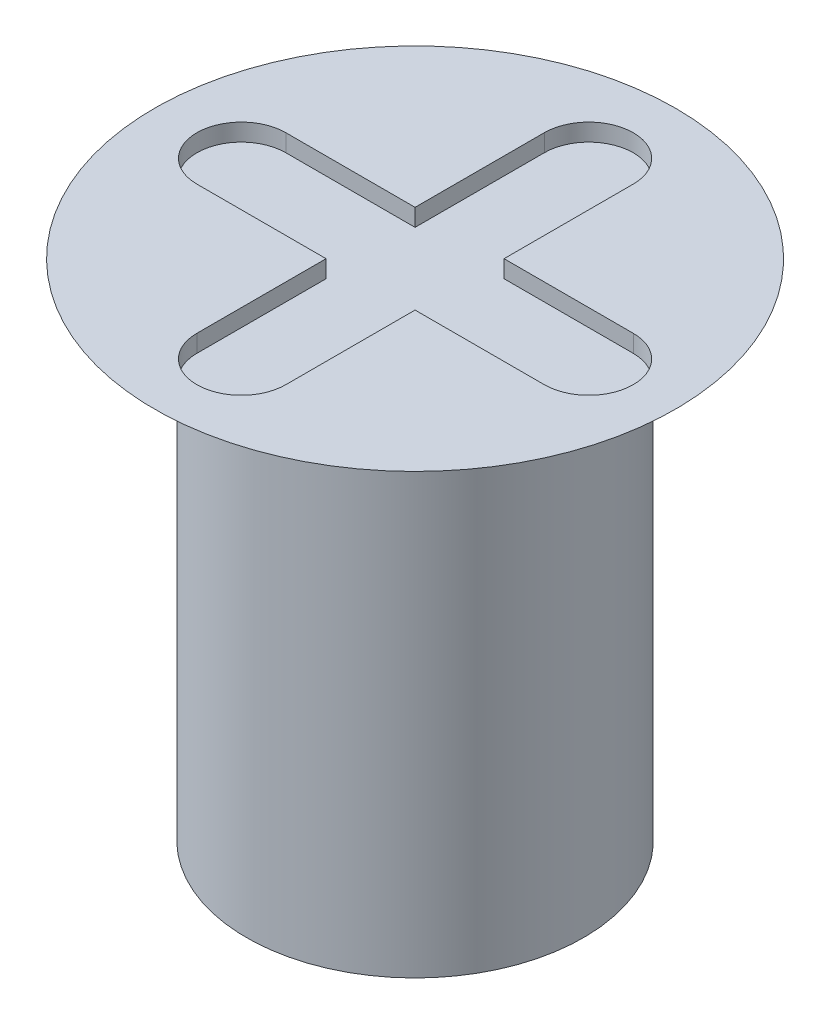
from build123d import *

# Parameters (mm, degrees)
CUT_EXTRUDE1_DEPTH = 0.1


with BuildPart() as part:
    # Sketch1 → Revolve1 (revolve)
    with BuildSketch(Plane.XY):
        Polygon((0, 2.9), (1.5, 2.9), (0.97, 2.594004357), (0.97, 0), (0, 0), align=None)
    revolve(axis=Axis((0, 0, 0), (0, 1, 0)))

    # Sketch2 → Cut-Extrude1 (cut)
    with BuildSketch(Plane(origin=(0, 2.9, 0), x_dir=(1, 0, 0), z_dir=(0, 1, 0))):
        with BuildLine():
            Line((0.256120786, 1), (0.256120786, 0.256120786))
            Line((0.256120786, 0.256120786), (1, 0.256120786))
            ThreePointArc((1, 0.256120786), (1.256120786, 0), (1, -0.256120786))
            Line((1, -0.256120786), (0.256120786, -0.256120786))
            Line((0.256120786, -0.256120786), (0.256120786, -1))
            ThreePointArc((0.256120786, -1), (0, -1.256120786), (-0.256120786, -1))
            Line((-0.256120786, -1), (-0.256120786, -0.256120786))
            Line((-0.256120786, -0.256120786), (-1, -0.256120786))
            ThreePointArc((-1, -0.256120786), (-1.256120786, 0), (-1, 0.256120786))
            Line((-1, 0.256120786), (-0.256120786, 0.256120786))
            Line((-0.256120786, 0.256120786), (-0.256120786, 1))
            ThreePointArc((-0.256120786, 1), (0, 1.256120786), (0.256120786, 1))
        make_face()
    extrude(amount=-CUT_EXTRUDE1_DEPTH, mode=Mode.SUBTRACT)


solid = part.part
